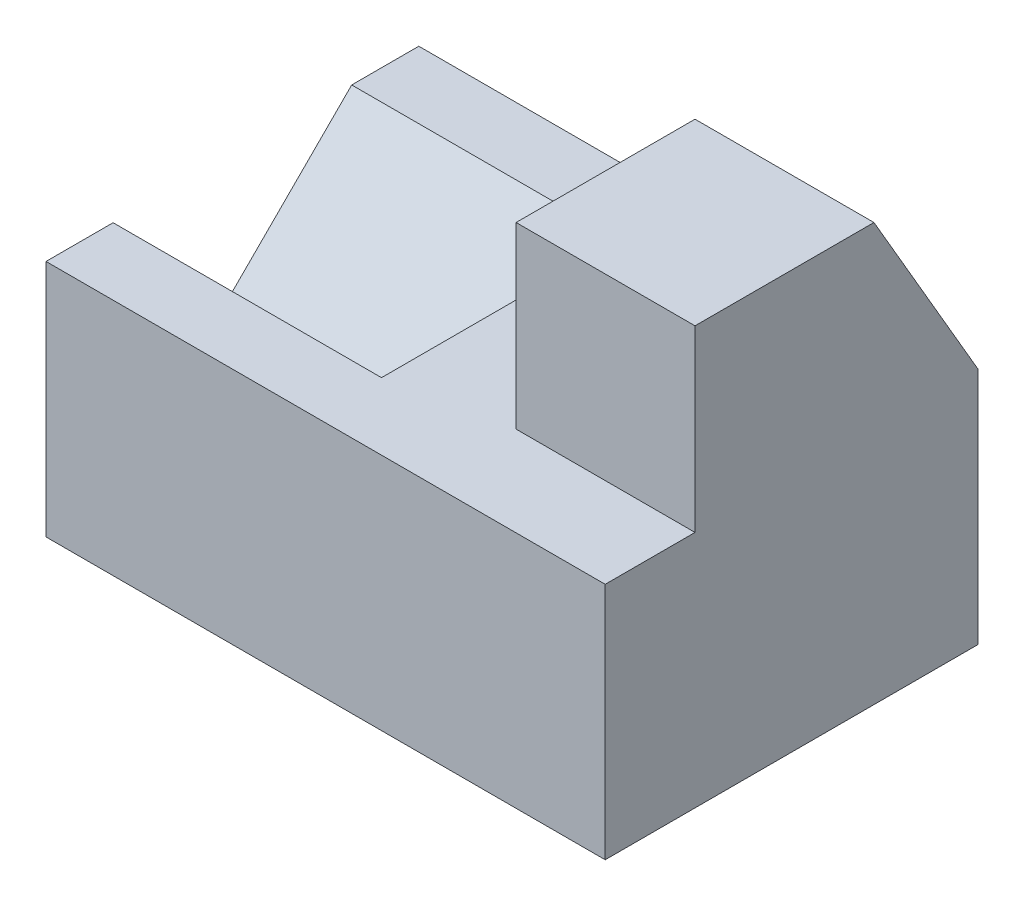
from build123d import *

# Parameters (mm, degrees)
BOSS_EXTRUDE1_DEPTH = 75
CUT_EXTRUDE1_DEPTH  = 51
CUT_EXTRUDE2_DEPTH  = 36


with BuildPart() as part:
    # Sketch1 → Boss-Extrude1 (new body)
    with BuildSketch(Plane(origin=(0, 0, 0), x_dir=(0, 0, -1), z_dir=(1, 0, 0))):
        Polygon((-21.916783927, 13.855955679), (-9.869343833, 13.855955679), (28.083216073, 13.855955679), (28.083216073, -18.144044321), (-21.916783927, -18.144044321), align=None)
        Polygon((14.130656167, 37.855955679), (28.083216073, 13.855955679), (-9.869343833, 13.855955679), (-9.869343833, 37.855955679), align=None)
    extrude(amount=-BOSS_EXTRUDE1_DEPTH)

    # Sketch2 → Cut-Extrude1 (cut)
    with BuildSketch(Plane.ZY.offset(75)):
        Polygon((-28.083216073, 13.855955679), (9.869343833, 13.855955679), (9.869343833, 37.855955679), (-14.130656167, 37.855955679), align=None)
    extrude(amount=-CUT_EXTRUDE1_DEPTH, mode=Mode.SUBTRACT)

    # Sketch3 → Cut-Extrude2 (cut)
    with BuildSketch(Plane.ZY.offset(75)):
        Polygon((-19.083216073, 13.855955679), (12.916783927, 13.855955679), (-3.083216073, -2.144044321), align=None)
    extrude(amount=-CUT_EXTRUDE2_DEPTH, mode=Mode.SUBTRACT)


solid = part.part
